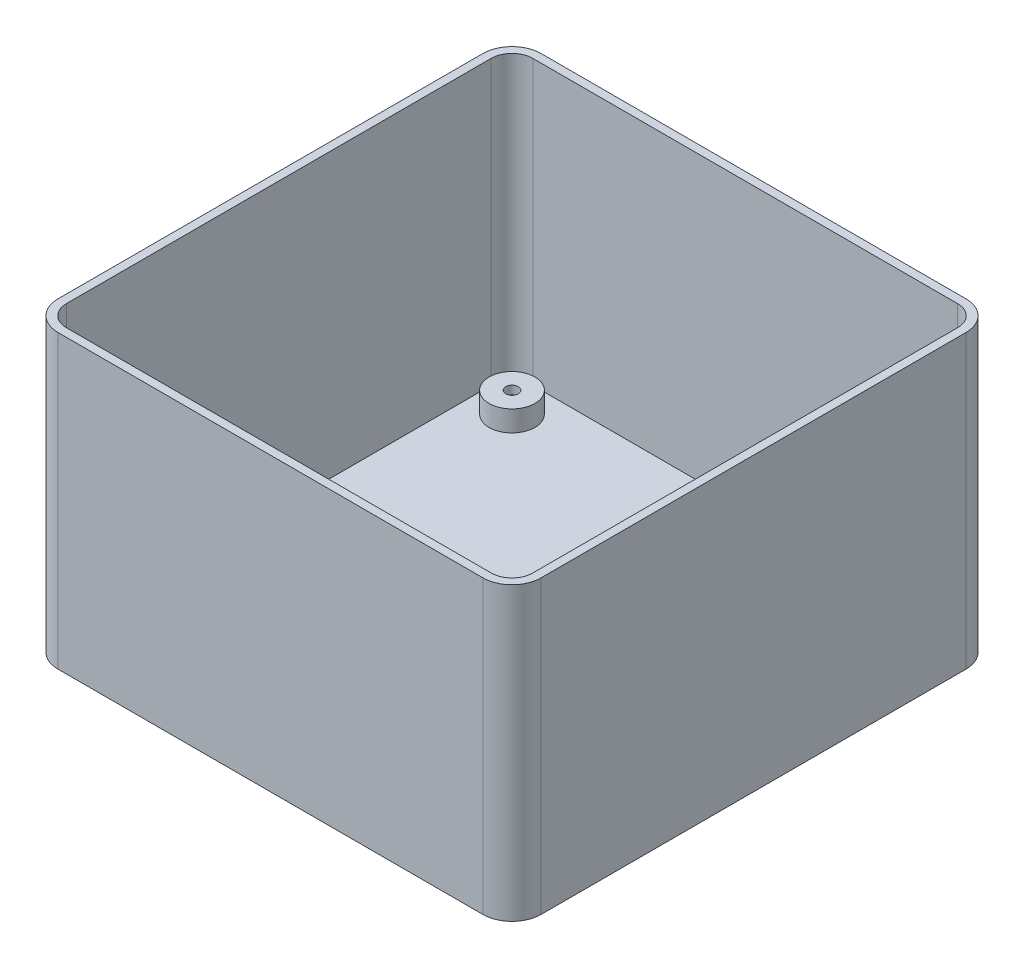
from build123d import *

# Parameters (mm, degrees)
BOSS_EXTRUDE1_DEPTH = 70
BOSS_EXTRUDE2_DEPTH = 2
SKETCH5_R           = 5.5
SKETCH5_R_2         = 1.5
BOSS_EXTRUDE3_DEPTH = 5
SKETCH8_R           = 4.5
CUT_EXTRUDE3_DEPTH  = 5


with BuildPart() as part:
    # Sketch1 → Boss-Extrude1 (new body)
    with BuildSketch(Plane(origin=(0, 0, 0), x_dir=(1, 0, 0), z_dir=(0, 1, 0))):
        with BuildLine():
            Line((-51, 58), (51, 58))
            ThreePointArc((51, 58), (55.949747468, 55.949747468), (58, 51))
            Line((58, 51), (58, -51))
            ThreePointArc((58, -51), (55.949747468, -55.949747468), (51, -58))
            Line((51, -58), (-51, -58))
            ThreePointArc((-51, -58), (-55.949747468, -55.949747468), (-58, -51))
            Line((-58, -51), (-58, 51))
            ThreePointArc((-58, 51), (-55.949747468, 55.949747468), (-51, 58))
        make_face()
        with BuildLine():
            Line((-51, -56), (51, -56))
            ThreePointArc((51, -56), (54.535533906, -54.535533906), (56, -51))
            Line((56, -51), (56, 51))
            ThreePointArc((56, 51), (54.535533906, 54.535533906), (51, 56))
            Line((51, 56), (-51, 56))
            ThreePointArc((-51, 56), (-54.535533906, 54.535533906), (-56, 51))
            Line((-56, 51), (-56, -51))
            ThreePointArc((-56, -51), (-54.535533906, -54.535533906), (-51, -56))
        make_face(mode=Mode.SUBTRACT)
    extrude(amount=BOSS_EXTRUDE1_DEPTH)

    # Sketch3 → Boss-Extrude2 (add)
    with BuildSketch(Plane(origin=(0, 0, 0), x_dir=(1, 0, 0), z_dir=(0, 1, 0))):
        with BuildLine():
            Line((51, 58), (-51, 58))
            ThreePointArc((-51, 58), (-55.949747468, 55.949747468), (-58, 51))
            Line((-58, 51), (-58, -51))
            ThreePointArc((-58, -51), (-55.949747468, -55.949747468), (-51, -58))
            Line((-51, -58), (51, -58))
            ThreePointArc((51, -58), (55.949747468, -55.949747468), (58, -51))
            Line((58, -51), (58, 51))
            ThreePointArc((58, 51), (55.949747468, 55.949747468), (51, 58))
        make_face()
    extrude(amount=BOSS_EXTRUDE2_DEPTH)

    # Sketch5 → Boss-Extrude3 (add)
    with BuildSketch(Plane(origin=(0, 2, 0), x_dir=(1, 0, 0), z_dir=(0, 1, 0))):
        with Locations((-47.5, 47.5)):
            Circle(SKETCH5_R)
        with Locations((-47.5, 47.5)):
            Circle(SKETCH5_R_2, mode=Mode.SUBTRACT)
    extrude(amount=BOSS_EXTRUDE3_DEPTH)

    # Sketch8 → Cut-Extrude3 (cut)
    with BuildSketch(Plane(origin=(0, 0, 0), x_dir=(1, 0, 0), z_dir=(0, 1, 0))):
        with Locations((-47.5, 47.5)):
            Circle(SKETCH8_R)
    extrude(amount=CUT_EXTRUDE3_DEPTH, mode=Mode.SUBTRACT)


solid = part.part
